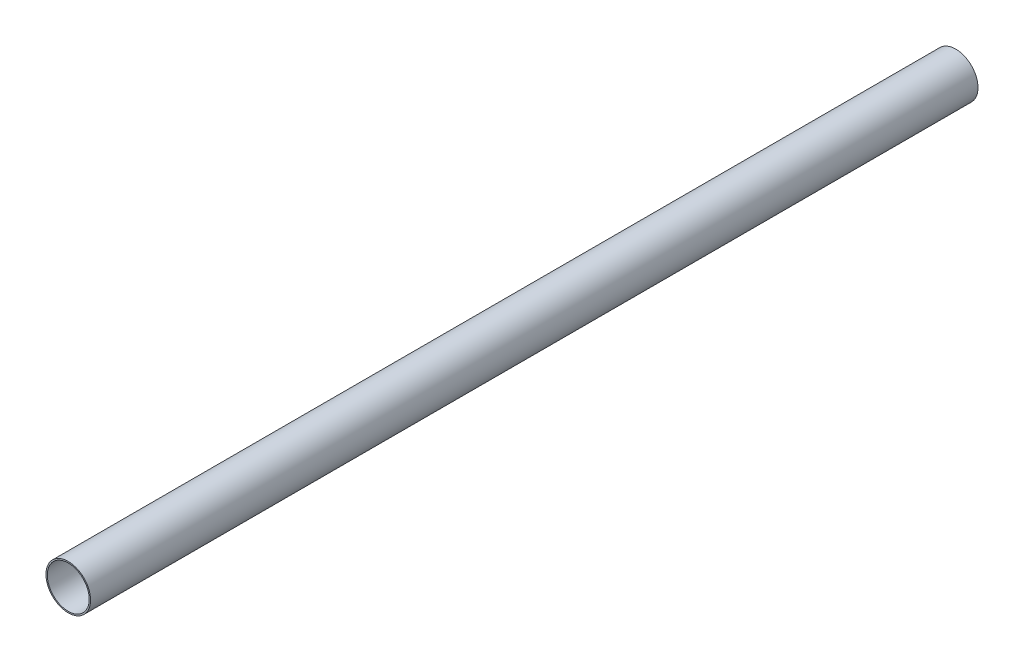
from build123d import *

# Parameters (mm, degrees)
SKETCH2_R           = 25
SKETCH2_R_2         = 23.5
BOSS_EXTRUDE1_DEPTH = 995


with BuildPart() as part:
    # Sketch2 → Boss-Extrude1 (new body)
    with BuildSketch(Plane.XY):
        Circle(SKETCH2_R)
        Circle(SKETCH2_R_2, mode=Mode.SUBTRACT)
    extrude(amount=BOSS_EXTRUDE1_DEPTH)


solid = part.part
